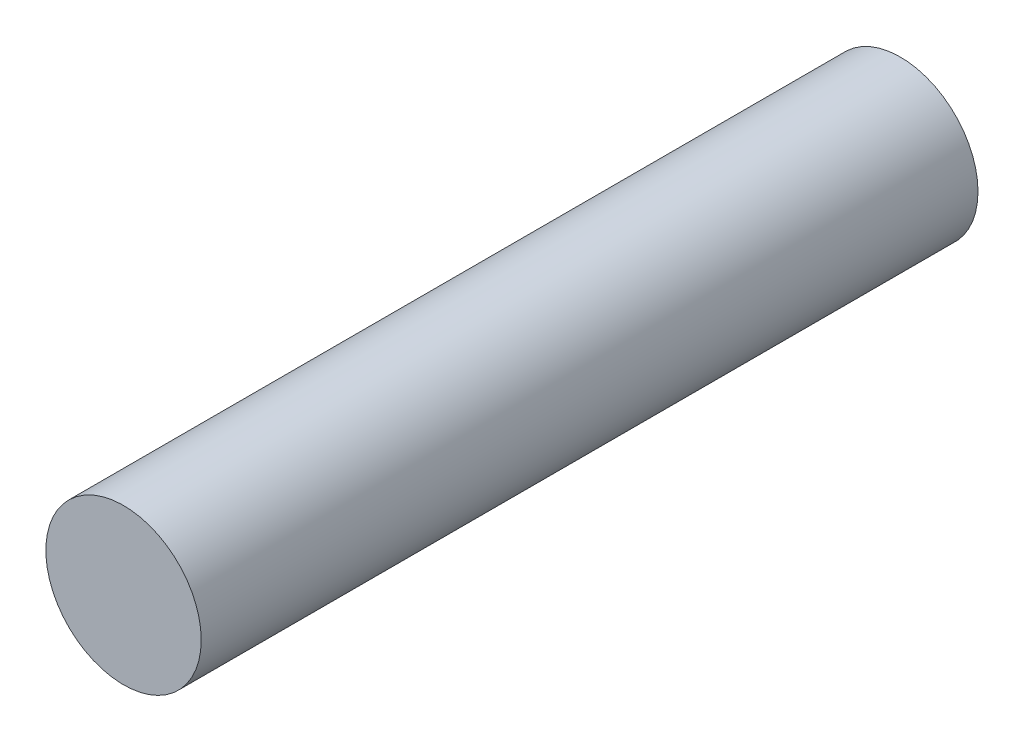
from build123d import *

# Parameters (mm, degrees)
SKETCH1_R           = 6.35
BOSS_EXTRUDE1_DEPTH = 31.75


with BuildPart() as part:
    # Sketch1 → Boss-Extrude1 (new body, symmetric)
    with BuildSketch(Plane.XY):
        Circle(SKETCH1_R)
    extrude(amount=BOSS_EXTRUDE1_DEPTH, both=True)


solid = part.part
